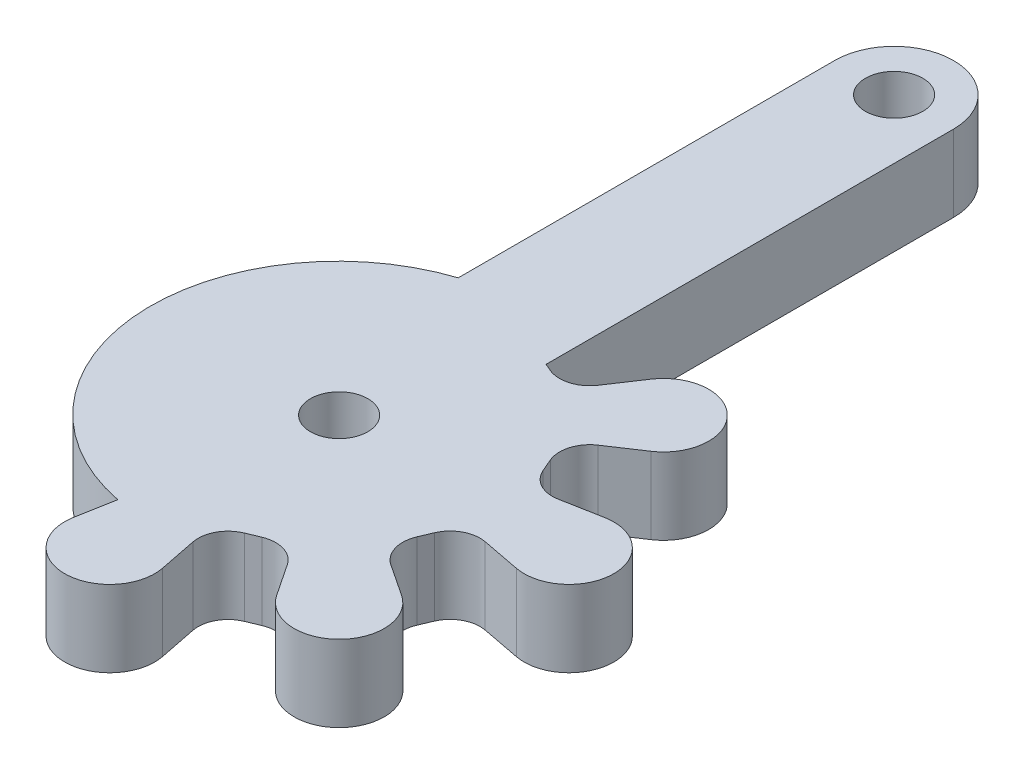
from build123d import *

# Parameters (mm, degrees)
CROQUIS1_R              = 1.500000449
CROQUIS1_R_2            = 1.500000067
SALIENTE_EXTRUIR1_DEPTH = 4


with BuildPart() as part:
    # Croquis1 → Saliente-Extruir1 (new body)
    with BuildSketch(Plane(origin=(0, 0, 0), x_dir=(1, 0, 0), z_dir=(0, 1, 0))):
        with BuildLine():
            Line((7.803034841, -10.666075678), (9.826177161, -11.05442464))
            ThreePointArc((9.826177161, -11.05442464), (12.611497219, -8.758438746), (9.837059372, -6.449314739))
            Line((9.837059372, -6.449314739), (7.783190104, -6.83350636))
            ThreePointArc((7.783190104, -6.83350636), (6.778877321, -6.678958506), (6.091539896, -5.930562574))
            Line((6.091539896, -5.930562574), (5.8088579, -5.271694401))
            ThreePointArc((5.8088579, -5.271694401), (5.746747512, -4.205872048), (6.380859817, -3.346956119))
            Line((6.380859817, -3.346956119), (8.045875641, -2.237519038))
            ThreePointArc((8.045875641, -2.237519038), (8.404769789, 1.386225416), (4.781168268, 1.025891001))
            Line((4.781168268, 1.025891001), (3.675334506, -0.635147383))
            ThreePointArc((3.675334506, -0.635147383), (2.774259756, -1.283481634), (1.669267023, -1.177349334))
            Line((1.669267023, -1.177349334), (1.3673448, -1.048666977))
            Line((1.3673448, -1.048666977), (1.3673448, 20.24263647))
            ThreePointArc((1.3673448, 20.24263647), (-1.737654981, 23.347636251), (-4.842654762, 20.24263647))
            Line((-4.842654762, 20.24263647), (-4.842654762, 0.571999527))
            ThreePointArc((-4.842654762, 0.571999527), (-11.591302814, -9.338185795), (-3.698262021, -18.363479735))
            Line((-3.698262021, -18.363479735), (-4.053895188, -20.326281833))
            ThreePointArc((-4.053895188, -20.326281833), (-1.716098294, -23.09980655), (0.570509604, -20.283930489))
            Line((0.570509604, -20.283930489), (0.177742699, -18.321752082))
            ThreePointArc((0.177742699, -18.321752082), (0.331674177, -17.275555509), (1.114410942, -16.564538403))
            Line((1.114410942, -16.564538403), (1.762991063, -16.295067607))
            ThreePointArc((1.762991063, -16.295067607), (2.82080022, -16.242583246), (3.671047948, -16.874084331))
            Line((3.671047948, -16.874084331), (4.780498307, -18.539119038))
            ThreePointArc((4.780498307, -18.539119038), (8.406487962, -18.895762792), (8.038611241, -15.270895558))
            Line((8.038611241, -15.270895558), (6.389450023, -14.179385265))
            ThreePointArc((6.389450023, -14.179385265), (5.741374186, -13.307833185), (5.800109712, -12.223326174))
            Line((5.800109712, -12.223326174), (6.067644855, -11.592044841))
            ThreePointArc((6.067644855, -11.592044841), (6.771618308, -10.822224208), (7.803034841, -10.666075678))
        make_face()
        with Locations((-1.73765539, 20.242635654)):
            Circle(CROQUIS1_R, mode=Mode.SUBTRACT)
        with Locations((-1.737655616, -8.757364808)):
            Circle(CROQUIS1_R_2, mode=Mode.SUBTRACT)
    extrude(amount=SALIENTE_EXTRUIR1_DEPTH)


solid = part.part
